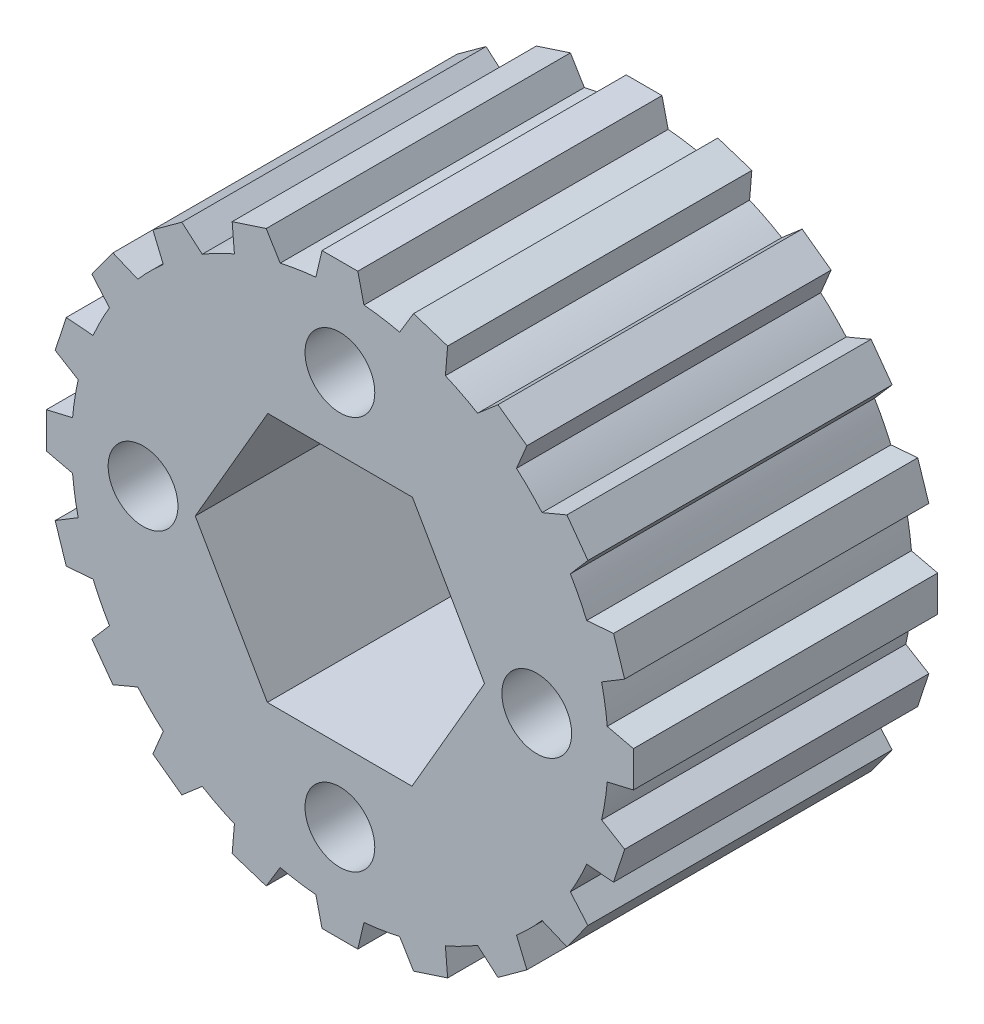
from build123d import *

# Parameters (mm, degrees)
SKETCH1_R                      = 15
EXTRUDE1_DEPTH                 = 17
EXTRUDE3_DEPTH                 = 17
CIRPATTERN1_COUNT              = 20
F_8_2_8_2_DIAMETER_HOLE1_D     = 8.2
F_8_2_8_2_DIAMETER_HOLE1_DEPTH = 10
F_8_2_8_2_DIAMETER_HOLE1_TIP   = 2.463528538
EXTRUDE5_DEPTH                 = 14
SKETCH7_R                      = 1.95
EXTRUDE6_DEPTH                 = 15


with BuildPart() as part:
    # Sketch1 → Extrude1 (new body)
    with BuildSketch(Plane.XY):
        Circle(SKETCH1_R)
    extrude(amount=EXTRUDE1_DEPTH)

    # Sketch2 → Extrude3 (add)
    with BuildSketch(Plane.XY.offset(17)):
        Polygon((1.4, 14.704480908), (1, 16.404480908), (-1, 16.404480908), (-1.4, 14.704480908), align=None)
    extrude3 = extrude(amount=-EXTRUDE3_DEPTH)

    # CirPattern1: Extrude3 ×20 about axis
    cirpattern1_axis = Axis((0, 0, 0), (0, 0, 1))
    for i in range(1, CIRPATTERN1_COUNT):
        add(extrude3.rotate(cirpattern1_axis, i * 360 / CIRPATTERN1_COUNT))

    # Ø8.2 (8.2) Diameter Hole1
    with Locations(Plane(origin=(0, 0, 0), x_dir=(-1, 0, 0), z_dir=(0, 0, -1))):
        with Locations((0, 0)):
            Hole(F_8_2_8_2_DIAMETER_HOLE1_D / 2, depth=F_8_2_8_2_DIAMETER_HOLE1_DEPTH)
            with Locations((0, 0, -(F_8_2_8_2_DIAMETER_HOLE1_DEPTH + F_8_2_8_2_DIAMETER_HOLE1_TIP / 2))):  # 118° drill point
                Cone(0, F_8_2_8_2_DIAMETER_HOLE1_D / 2, F_8_2_8_2_DIAMETER_HOLE1_TIP, mode=Mode.SUBTRACT)

    # Sketch6 → Extrude5 (cut)
    with BuildSketch(Plane.XY.offset(17)):
        Polygon((4.053764157, 6.992877054), (-4.029127096, 7.007101268), (-8.082891253, 0.014224214), (-4.053764157, -6.992877054), (4.029127096, -7.007101268), (8.082891253, -0.014224214), align=None)
    extrude(amount=-EXTRUDE5_DEPTH, mode=Mode.SUBTRACT)

    # Sketch7 → Extrude6 (cut)
    with BuildSketch(Plane.XY.offset(17)):
        with Locations((-11, 0)):
            Circle(SKETCH7_R)
        with Locations((0, 11)):
            Circle(SKETCH7_R)
        with Locations((11, 0)):
            Circle(SKETCH7_R)
        with Locations((0, -11)):
            Circle(SKETCH7_R)
    extrude(amount=-EXTRUDE6_DEPTH, mode=Mode.SUBTRACT)


solid = part.part
